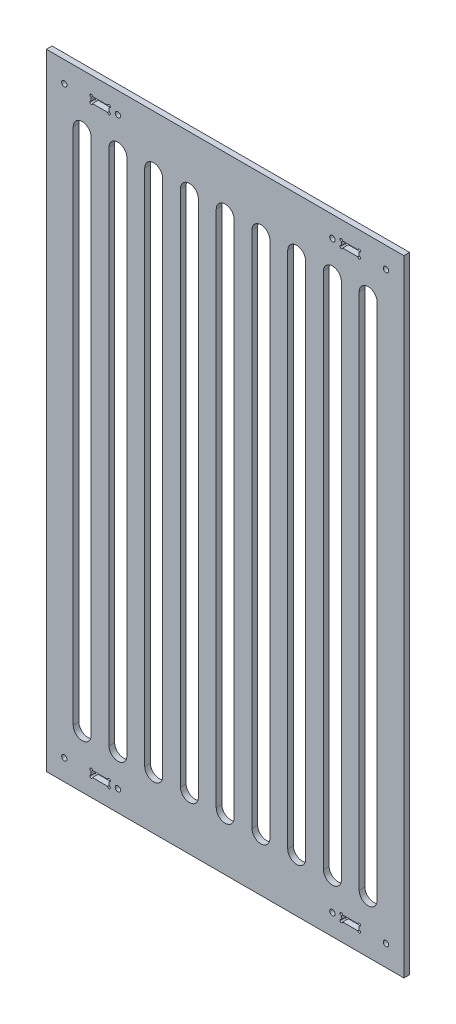
from build123d import *

# Parameters (mm, degrees)
SKETCH1_W                 = 400
SKETCH1_H                 = 700
BOSS_EXTRUDE1_DEPTH       = 6.35
SKETCH2_R                 = 1.5
SKETCH2_W                 = 20
SKETCH2_H                 = 6.858
SKETCH2_R_2               = 3
CUT_EXTRUDE1_DEPTH        = 7.35
MIRROR2_COPY_1_SKETCH_R   = 1.5
MIRROR2_COPY_1_SKETCH_W   = 20
MIRROR2_COPY_1_SKETCH_H   = 6.858
MIRROR2_COPY_1_SKETCH_R_2 = 3
MIRROR2_COPY_1_DEPTH      = 7.35
CUT_EXTRUDE2_DEPTH        = 7.35
LPATTERN1_COUNT           = 5
LPATTERN1_PITCH           = 40
MIRROR3_COPY_1_DEPTH      = 7.35
MIRROR3_COPY_2_DEPTH      = 7.35
MIRROR3_COPY_3_DEPTH      = 7.35
MIRROR3_COPY_4_DEPTH      = 7.35
MIRROR3_COPY_5_DEPTH      = 7.35


with BuildPart() as part:
    # Sketch1 → Boss-Extrude1 (new body)
    with BuildSketch(Plane.XY):
        Rectangle(SKETCH1_W, SKETCH1_H)
    extrude(amount=BOSS_EXTRUDE1_DEPTH)

    # Sketch2 → Cut-Extrude1 (cut, through all)
    with BuildSketch(Plane.XY.offset(6.35)):
        with Locations((-130, 323.142)):
            Circle(SKETCH2_R)
        with Locations((-130, 330)):
            Circle(SKETCH2_R)
        with Locations((-150, 330)):
            Circle(SKETCH2_R)
        with Locations((-150, 323.142)):
            Circle(SKETCH2_R)
        with Locations((-140, 326.571)):
            Rectangle(SKETCH2_W, SKETCH2_H)
        with BuildLine():
            Line((-150, 328.5), (-150, 330))
            Line((-150, 330), (-148.5, 330))
            ThreePointArc((-148.5, 330), (-151.060660172, 331.060660172), (-150, 328.5))
        make_face()
        with BuildLine():
            Line((-148.5, 330), (-150, 330))
            Line((-150, 330), (-150, 328.5))
            ThreePointArc((-150, 328.5), (-148.939339828, 328.939339828), (-148.5, 330))
        make_face()
        with BuildLine():
            ThreePointArc((-148.5, 323.142), (-148.939339828, 324.202660172), (-150, 324.642))
            Line((-150, 324.642), (-150, 323.142))
            Line((-150, 323.142), (-148.5, 323.142))
        make_face()
        with BuildLine():
            Line((-150, 323.142), (-150, 324.642))
            ThreePointArc((-150, 324.642), (-151.060660172, 322.081339828), (-148.5, 323.142))
            Line((-148.5, 323.142), (-150, 323.142))
        make_face()
        with BuildLine():
            ThreePointArc((-128.5, 330), (-130, 331.5), (-131.5, 330))
            Line((-131.5, 330), (-130, 330))
            Line((-130, 330), (-130, 328.5))
            ThreePointArc((-130, 328.5), (-128.939339828, 328.939339828), (-128.5, 330))
        make_face()
        with BuildLine():
            Line((-130, 330), (-131.5, 330))
            ThreePointArc((-131.5, 330), (-131.060660172, 328.939339828), (-130, 328.5))
            Line((-130, 328.5), (-130, 330))
        make_face()
        with BuildLine():
            ThreePointArc((-128.5, 323.142), (-128.939339828, 324.202660172), (-130, 324.642))
            Line((-130, 324.642), (-130, 323.142))
            Line((-130, 323.142), (-131.5, 323.142))
            ThreePointArc((-131.5, 323.142), (-130, 321.642), (-128.5, 323.142))
        make_face()
        with BuildLine():
            Line((-130, 323.142), (-130, 324.642))
            ThreePointArc((-130, 324.642), (-131.060660172, 324.202660172), (-131.5, 323.142))
            Line((-131.5, 323.142), (-130, 323.142))
        make_face()
        with Locations((-180, 326.57)):
            Circle(SKETCH2_R_2)
        with Locations((-120, 326.57)):
            Circle(SKETCH2_R_2)
    cut_extrude1 = extrude(amount=-CUT_EXTRUDE1_DEPTH, mode=Mode.SUBTRACT)

    # Mirror1: Cut-Extrude1 across plane
    add(cut_extrude1.mirror(Plane.ZX), mode=Mode.SUBTRACT)

    # Mirror2: Cut-Extrude1 across plane
    add(cut_extrude1.mirror(Plane(origin=(0, 0, 0), x_dir=(0, 0, 1), z_dir=(1, 0, 0))), mode=Mode.SUBTRACT)

    # Mirror2 copy 1 sketch → Mirror2 copy 1 (cut, through all)
    with BuildSketch(Plane(origin=(0, 0, 6.35), x_dir=(-1, 0, 0), z_dir=(0, 0, 1))):
        with Locations((-130, 323.142)):
            Circle(MIRROR2_COPY_1_SKETCH_R)
        with Locations((-130, 330)):
            Circle(MIRROR2_COPY_1_SKETCH_R)
        with Locations((-150, 330)):
            Circle(MIRROR2_COPY_1_SKETCH_R)
        with Locations((-150, 323.142)):
            Circle(MIRROR2_COPY_1_SKETCH_R)
        with Locations((-140, 326.571)):
            Rectangle(MIRROR2_COPY_1_SKETCH_W, MIRROR2_COPY_1_SKETCH_H)
        with BuildLine():
            Line((-150, 328.5), (-150, 330))
            Line((-150, 330), (-148.5, 330))
            ThreePointArc((-148.5, 330), (-151.060660172, 331.060660172), (-150, 328.5))
        make_face()
        with BuildLine():
            Line((-148.5, 330), (-150, 330))
            Line((-150, 330), (-150, 328.5))
            ThreePointArc((-150, 328.5), (-148.939339828, 328.939339828), (-148.5, 330))
        make_face()
        with BuildLine():
            ThreePointArc((-148.5, 323.142), (-148.939339828, 324.202660172), (-150, 324.642))
            Line((-150, 324.642), (-150, 323.142))
            Line((-150, 323.142), (-148.5, 323.142))
        make_face()
        with BuildLine():
            Line((-150, 323.142), (-150, 324.642))
            ThreePointArc((-150, 324.642), (-151.060660172, 322.081339828), (-148.5, 323.142))
            Line((-148.5, 323.142), (-150, 323.142))
        make_face()
        with BuildLine():
            ThreePointArc((-128.5, 330), (-130, 331.5), (-131.5, 330))
            Line((-131.5, 330), (-130, 330))
            Line((-130, 330), (-130, 328.5))
            ThreePointArc((-130, 328.5), (-128.939339828, 328.939339828), (-128.5, 330))
        make_face()
        with BuildLine():
            Line((-130, 330), (-131.5, 330))
            ThreePointArc((-131.5, 330), (-131.060660172, 328.939339828), (-130, 328.5))
            Line((-130, 328.5), (-130, 330))
        make_face()
        with BuildLine():
            ThreePointArc((-128.5, 323.142), (-128.939339828, 324.202660172), (-130, 324.642))
            Line((-130, 324.642), (-130, 323.142))
            Line((-130, 323.142), (-131.5, 323.142))
            ThreePointArc((-131.5, 323.142), (-130, 321.642), (-128.5, 323.142))
        make_face()
        with BuildLine():
            Line((-130, 323.142), (-130, 324.642))
            ThreePointArc((-130, 324.642), (-131.060660172, 324.202660172), (-131.5, 323.142))
            Line((-131.5, 323.142), (-130, 323.142))
        make_face()
        with Locations((-180, 326.57)):
            Circle(MIRROR2_COPY_1_SKETCH_R_2)
        with Locations((-120, 326.57)):
            Circle(MIRROR2_COPY_1_SKETCH_R_2)
    extrude(amount=-MIRROR2_COPY_1_DEPTH, mode=Mode.SUBTRACT)

    # Sketch3 → Cut-Extrude2 (cut, through all)
    with BuildSketch(Plane.XY.offset(6.35)):
        with BuildLine():
            Line((10, 290), (10, -290))
            ThreePointArc((10, -290), (0, -300), (-10, -290))
            Line((-10, -290), (-10, 290))
            ThreePointArc((-10, 290), (0, 300), (10, 290))
        make_face()
    cut_extrude2 = extrude(amount=-CUT_EXTRUDE2_DEPTH, mode=Mode.SUBTRACT)

    # LPattern1: Cut-Extrude2 ×5
    with Locations(*[(i * LPATTERN1_PITCH, 0, 0) for i in range(1, LPATTERN1_COUNT)]):
        add(cut_extrude2, mode=Mode.SUBTRACT)

    # Mirror3 copy 1 sketch → Mirror3 copy 1 (cut, through all)
    with BuildSketch(Plane(origin=(-40, 0, 6.35), x_dir=(-1, 0, 0), z_dir=(0, 0, 1))):
        with BuildLine():
            Line((10, -290), (10, 290))
            ThreePointArc((10, 290), (0, 300), (-10, 290))
            Line((-10, 290), (-10, -290))
            ThreePointArc((-10, -290), (0, -300), (10, -290))
        make_face()
    extrude(amount=-MIRROR3_COPY_1_DEPTH, mode=Mode.SUBTRACT)

    # Mirror3 copy 2 sketch → Mirror3 copy 2 (cut, through all)
    with BuildSketch(Plane(origin=(-80, 0, 6.35), x_dir=(-1, 0, 0), z_dir=(0, 0, 1))):
        with BuildLine():
            Line((10, -290), (10, 290))
            ThreePointArc((10, 290), (0, 300), (-10, 290))
            Line((-10, 290), (-10, -290))
            ThreePointArc((-10, -290), (0, -300), (10, -290))
        make_face()
    extrude(amount=-MIRROR3_COPY_2_DEPTH, mode=Mode.SUBTRACT)

    # Mirror3 copy 3 sketch → Mirror3 copy 3 (cut, through all)
    with BuildSketch(Plane(origin=(-120, 0, 6.35), x_dir=(-1, 0, 0), z_dir=(0, 0, 1))):
        with BuildLine():
            Line((10, -290), (10, 290))
            ThreePointArc((10, 290), (0, 300), (-10, 290))
            Line((-10, 290), (-10, -290))
            ThreePointArc((-10, -290), (0, -300), (10, -290))
        make_face()
    extrude(amount=-MIRROR3_COPY_3_DEPTH, mode=Mode.SUBTRACT)

    # Mirror3 copy 4 sketch → Mirror3 copy 4 (cut, through all)
    with BuildSketch(Plane(origin=(-160, 0, 6.35), x_dir=(-1, 0, 0), z_dir=(0, 0, 1))):
        with BuildLine():
            Line((10, -290), (10, 290))
            ThreePointArc((10, 290), (0, 300), (-10, 290))
            Line((-10, 290), (-10, -290))
            ThreePointArc((-10, -290), (0, -300), (10, -290))
        make_face()
    extrude(amount=-MIRROR3_COPY_4_DEPTH, mode=Mode.SUBTRACT)

    # Mirror3 copy 5 sketch → Mirror3 copy 5 (cut, through all)
    with BuildSketch(Plane(origin=(0, 0, 6.35), x_dir=(-1, 0, 0), z_dir=(0, 0, 1))):
        with BuildLine():
            Line((10, -290), (10, 290))
            ThreePointArc((10, 290), (0, 300), (-10, 290))
            Line((-10, 290), (-10, -290))
            ThreePointArc((-10, -290), (0, -300), (10, -290))
        make_face()
    extrude(amount=-MIRROR3_COPY_5_DEPTH, mode=Mode.SUBTRACT)


solid = part.part
